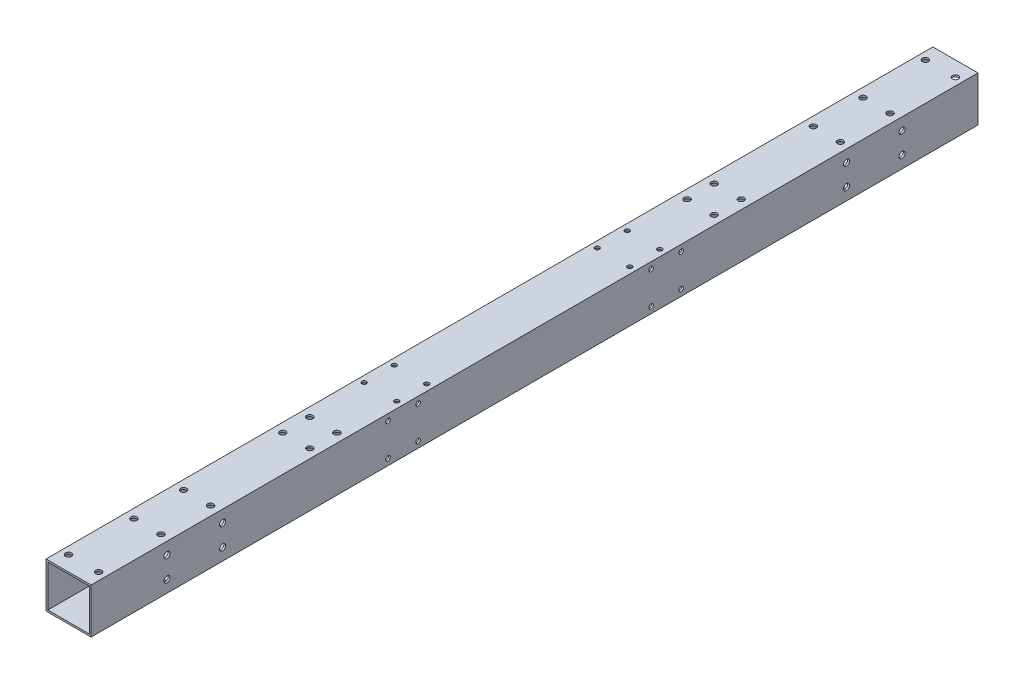
from build123d import *

# Parameters (mm, degrees)
SKETCH_1_W               = 30
SKETCH_1_H               = 30
SKETCH_1_W_2             = 27.6
SKETCH_1_H_2             = 27.6
EXTRUDE_1_DEPTH          = 295
SKETCH_2_R               = 2.025
CUT_EXTRUDE_1_DEPTH      = 35
SKETCH_3_R               = 3.8
CUT_EXTRUDE_2_DEPTH      = 5
SKETCH_4_R               = 2.025
CUT_EXTRUDE_3_DEPTH      = 5
SKETCH_5_R               = 1.525
CUT_EXTRUDE_4_DEPTH      = 50
SKETCH_6_R               = 2.025
CUT_EXTRUDE_5_DEPTH      = 30
SKETCH_7_R               = 2.025
CUT_EXTRUDE_6_DEPTH      = 90
SKETCH_8_R               = 3.9
CUT_EXTRUDE_7_DEPTH      = 10
SKETCH_9_R               = 1.525
CUT_EXTRUDE_8_DEPTH      = 50
MIRROR_8_COPY_1_SKETCH_R = 1.525
MIRROR_8_COPY_1_DEPTH    = 50


with BuildPart() as part:
    # 草图1 → 凸台-拉伸1 (new body, symmetric)
    with BuildSketch(Plane.XY):
        Rectangle(SKETCH_1_W, SKETCH_1_H)
        Rectangle(SKETCH_1_W_2, SKETCH_1_H_2, mode=Mode.SUBTRACT)
    extrude(amount=EXTRUDE_1_DEPTH, both=True)

    # 草图2 → 切除-拉伸1 (cut, symmetric)
    with BuildSketch(Plane.XZ.offset(15)):
        with Locations((-9, 209.5)):
            Circle(SKETCH_2_R)
        with Locations((9, 209.5)):
            Circle(SKETCH_2_R)
        with Locations((-9, 242.5)):
            Circle(SKETCH_2_R)
        with Locations((9, 242.5)):
            Circle(SKETCH_2_R)
    cut_extrude_1 = extrude(amount=CUT_EXTRUDE_1_DEPTH, both=True, mode=Mode.SUBTRACT)

    # 镜向1: 切除-拉伸1 across plane
    add(cut_extrude_1.mirror(Plane.XY), mode=Mode.SUBTRACT)

    # 草图3 → 切除-拉伸2 (cut, symmetric)
    with BuildSketch(Plane.XZ.offset(15)):
        with Locations((9, 242.5)):
            Circle(SKETCH_3_R)
        with Locations((9, 209.5)):
            Circle(SKETCH_3_R)
        with Locations((-9, 242.5)):
            Circle(SKETCH_3_R)
        with Locations((-9, 209.5)):
            Circle(SKETCH_3_R)
    cut_extrude_2 = extrude(amount=CUT_EXTRUDE_2_DEPTH, both=True, mode=Mode.SUBTRACT)

    # 镜向2: 切除-拉伸2 across plane
    add(cut_extrude_2.mirror(Plane.XY), mode=Mode.SUBTRACT)

    # 草图4 → 切除-拉伸3 (cut, symmetric)
    with BuildSketch(Plane.XZ.offset(-13.8)):
        with Locations((-10, 285)):
            Circle(SKETCH_4_R)
        with Locations((10, 285)):
            Circle(SKETCH_4_R)
    cut_extrude_3 = extrude(amount=CUT_EXTRUDE_3_DEPTH, both=True, mode=Mode.SUBTRACT)

    # 镜向3: 切除-拉伸3 across plane
    add(cut_extrude_3.mirror(Plane.XY), mode=Mode.SUBTRACT)

    # 草图5 → 切除-拉伸4 (cut)
    with BuildSketch(Plane.XZ.offset(15)):
        with Locations((10.8, 67.5)):
            Circle(SKETCH_5_R)
        with Locations((10.8, 87.5)):
            Circle(SKETCH_5_R)
        with Locations((10.8, -87.5)):
            Circle(SKETCH_5_R)
        with Locations((10.8, -67.5)):
            Circle(SKETCH_5_R)
    cut_extrude_4 = extrude(amount=-CUT_EXTRUDE_4_DEPTH, mode=Mode.SUBTRACT)

    # 镜向4: 切除-拉伸4 across plane
    add(cut_extrude_4.mirror(Plane(origin=(0, 0, 0), x_dir=(0, 0, 1), z_dir=(1, 0, 0))), mode=Mode.SUBTRACT)

    # 草图6 → 切除-拉伸5 (cut)
    with BuildSketch(Plane.ZY.offset(15)):
        with Locations((244.5, 7)):
            Circle(SKETCH_6_R)
        with Locations((207.5, 7)):
            Circle(SKETCH_6_R)
        with Locations((207.5, -7)):
            Circle(SKETCH_6_R)
        with Locations((244.5, -7)):
            Circle(SKETCH_6_R)
        with Locations((-244.5, -7)):
            Circle(SKETCH_6_R)
        with Locations((-207.5, -7)):
            Circle(SKETCH_6_R)
        with Locations((-207.5, 7)):
            Circle(SKETCH_6_R)
        with Locations((-244.5, 7)):
            Circle(SKETCH_6_R)
    extrude(amount=-CUT_EXTRUDE_5_DEPTH, mode=Mode.SUBTRACT)

    # 草图7 → 切除-拉伸6 (cut)
    with BuildSketch(Plane.XZ.offset(15)):
        with Locations((-9, 143.5)):
            Circle(SKETCH_7_R)
        with Locations((-9, 125.5)):
            Circle(SKETCH_7_R)
        with Locations((9, 125.5)):
            Circle(SKETCH_7_R)
        with Locations((9, 143.5)):
            Circle(SKETCH_7_R)
    cut_extrude_6 = extrude(amount=-CUT_EXTRUDE_6_DEPTH, mode=Mode.SUBTRACT)

    # 镜向5: 切除-拉伸6 across plane
    add(cut_extrude_6.mirror(Plane.XY), mode=Mode.SUBTRACT)

    # 草图8 → 切除-拉伸7 (cut)
    with BuildSketch(Plane.XZ.offset(15)):
        with Locations((-9, -125.5)):
            Circle(SKETCH_8_R)
        with Locations((-9, -143.5)):
            Circle(SKETCH_8_R)
        with Locations((9, -143.5)):
            Circle(SKETCH_8_R)
        with Locations((9, -125.5)):
            Circle(SKETCH_8_R)
    cut_extrude_7 = extrude(amount=-CUT_EXTRUDE_7_DEPTH, mode=Mode.SUBTRACT)

    # 镜向6: 切除-拉伸7 across plane
    add(cut_extrude_7.mirror(Plane.XY), mode=Mode.SUBTRACT)

    # 草图9 → 切除-拉伸8 (cut)
    with BuildSketch(Plane.ZY.offset(15)):
        with Locations((97.5, -10.8)):
            Circle(SKETCH_9_R)
        with Locations((77.5, -10.8)):
            Circle(SKETCH_9_R)
    cut_extrude_8 = extrude(amount=-CUT_EXTRUDE_8_DEPTH, mode=Mode.SUBTRACT)

    # 镜向7: 切除-拉伸8 across plane
    add(cut_extrude_8.mirror(Plane.XY), mode=Mode.SUBTRACT)

    # 镜向8: 切除-拉伸8 across plane
    add(cut_extrude_8.mirror(Plane.ZX), mode=Mode.SUBTRACT)

    # 镜向8 copy 1 sketch → 镜向8 copy 1 (cut)
    with BuildSketch(Plane(origin=(-15, 0, 0), x_dir=(0, 0, -1), z_dir=(-1, 0, 0))):
        with Locations((97.5, -10.8)):
            Circle(MIRROR_8_COPY_1_SKETCH_R)
        with Locations((77.5, -10.8)):
            Circle(MIRROR_8_COPY_1_SKETCH_R)
    extrude(amount=-MIRROR_8_COPY_1_DEPTH, mode=Mode.SUBTRACT)


solid = part.part
